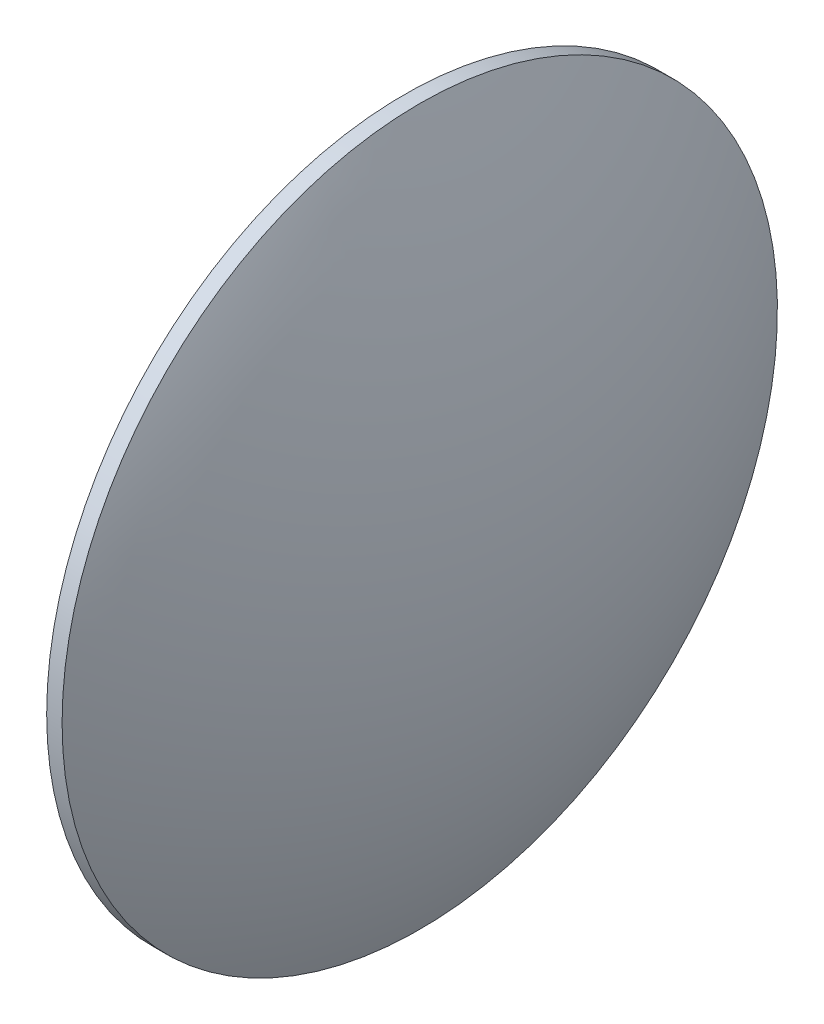
from build123d import *


with BuildPart() as part:
    # 草图1 → 旋转1 (revolve)
    with BuildSketch(Plane.XY):
        with BuildLine():
            Line((390.724370014, 50.663195772), (390.724370014, 73.163195772))
            Line((390.724370014, 73.163195772), (391.694370014, 73.163195772))
            ThreePointArc((391.694370014, 73.163195772), (395.52562228, 62.201901289), (396.824370014, 50.663195772))
            Line((396.824370014, 50.663195772), (390.724370014, 50.663195772))
        make_face()
    revolve(axis=Axis((381.289590128, 50.663195772, 0), (1, 0, 0)))


solid = part.part
